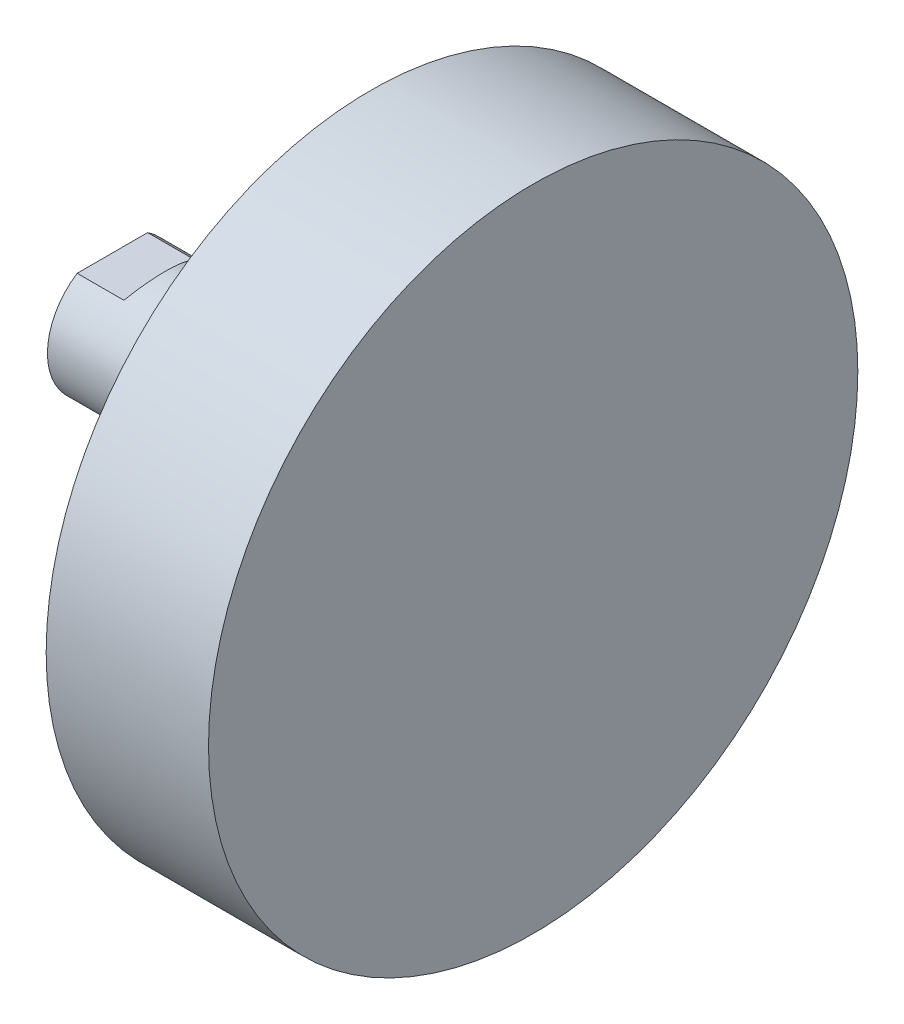
from build123d import *

# Parameters (mm, degrees)
SKETCH1_W               = 81
SKETCH1_H               = 12.5
SKETCH2_W               = 31.25
SKETCH2_H               = 62.5
CUT_EXTRUDE1_DEPTH      = 25
CUT_EXTRUDE1_DEPTH_BACK = 25


with BuildPart() as part:
    # Sketch1 → Revolve1 (revolve)
    with BuildSketch(Plane.XY):
        with Locations((29.5, 6.25)):
            Rectangle(SKETCH1_W, SKETCH1_H)
    revolve(axis=Axis((70, 0, 0), (-1, 0, 0)))

    # Sketch2 → Revolve2 (revolve)
    with BuildSketch(Plane.XY):
        with Locations((54.375, 31.25)):
            Rectangle(SKETCH2_W, SKETCH2_H)
    revolve(axis=Axis((70, 0, 0), (-1, 0, 0)))

    # Sketch3 → Cut-Extrude1 (cut, two sides: drawn at the far end of the back side and taken through both)
    with BuildSketch(Plane.XY.offset(-CUT_EXTRUDE1_DEPTH_BACK)):
        Polygon((-67, -28), (8.103629711, -28), (-2, -10.5), (-11, -10.5), (-11, -15.5), (-56, -15.5), (-56, 15.5), (-11, 15.5), (-11, 10.5), (-2, 10.5), (8.103629711, 28), (-67, 28), align=None)
    extrude(amount=CUT_EXTRUDE1_DEPTH + CUT_EXTRUDE1_DEPTH_BACK, mode=Mode.SUBTRACT)

    # Sketch4 → Cut-Revolve1 (revolve, cut)
    with BuildSketch(Plane.XY):
        Polygon((-11, 0), (-11, 9.5), (-10, 8.5), (-4, 8.5), (-4, 8), (-2.9175, 6.9175), (20.5, 6.9175), (24.493820487, 0), align=None)
    revolve(axis=Axis((24.493820487, 0, 0), (-1, 0, 0)), mode=Mode.SUBTRACT)


solid = part.part
